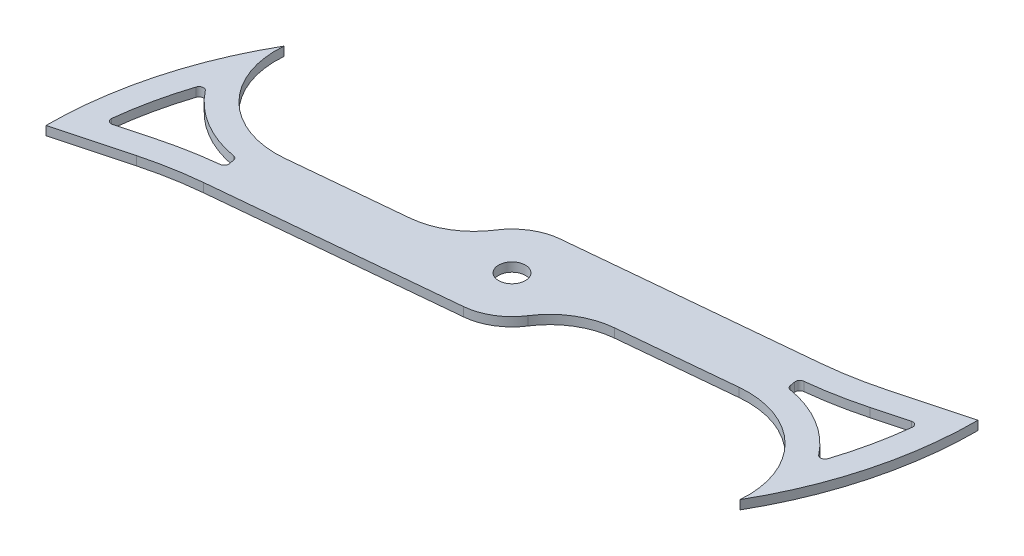
from build123d import *

# Parameters (mm, degrees)
SKETCH1_R           = 76.2
SKETCH1_R_2         = 19.05
BOSS_EXTRUDE1_DEPTH = 12.7
CIRPATTERN1_COUNT   = 2
FILLET1_R           = 101.6
CUT_EXTRUDE2_DEPTH  = 13.7
FILLET2_R           = 6.35


with BuildPart() as part:
    # Sketch1 → Boss-Extrude1 (new body)
    with BuildSketch(Plane(origin=(0, 0, 0), x_dir=(1, 0, 0), z_dir=(0, 1, 0))):
        with BuildLine():
            ThreePointArc((-461.937950379, 266.7), (-515.224835743, 138.054078658), (-533.4, 0))
            Line((-533.4, 0), (-431.8, 27.223637951))
            ThreePointArc((-431.8, 27.223637951), (-391.951998133, 36.135119544), (-351.499222019, 41.689456733))
            Line((-351.499222019, 41.689456733), (-14.198340678, 73.716868009))
            ThreePointArc((-14.198340678, 73.716868009), (-73.012974959, 93.516111014), (-97.595715318, 150.497336919))
            Line((-97.595715318, 150.497336919), (-323.429158368, 129.053987789))
            ThreePointArc((-323.429158368, 129.053987789), (-424.955630689, 165.402632783), (-461.937950379, 266.7))
        make_face()
        with Locations((-21.401289496, 149.575667949)):
            Circle(SKETCH1_R)
        with Locations((-21.401289496, 149.575667949)):
            Circle(SKETCH1_R_2, mode=Mode.SUBTRACT)
    boss_extrude1 = extrude(amount=BOSS_EXTRUDE1_DEPTH)

    # CirPattern1: Boss-Extrude1 ×2 about axis
    cirpattern1_axis = Axis((-21.401289496, 0, -149.575667949), (0, 1, 0))
    for i in range(1, CIRPATTERN1_COUNT):
        add(boss_extrude1.rotate(cirpattern1_axis, i * 360 / CIRPATTERN1_COUNT))

    # Fillet1
    fillet1_edges = [part.edges().sort_by_distance(p)[0] for p in [
        (-97.595715318, 6.35, -150.497336919),
        (54.793136326, 6.35, -148.653998979),
    ]]
    fillet(fillet1_edges, radius=FILLET1_R)

    # Sketch3 → Cut-Extrude2 (cut, through all)
    with BuildSketch(Plane(origin=(0, 12.7, 0), x_dir=(1, 0, 0), z_dir=(0, 1, 0))):
        with BuildLine():
            ThreePointArc((-354.80057356, 76.458073372), (-356.713011165, 85.800166676), (-358.363729661, 95.192038339))
            ThreePointArc((-358.363729661, 95.192038339), (-421.769213749, 118.496456117), (-470.148687166, 165.642801175))
            ThreePointArc((-470.148687166, 165.642801175), (-486.927538331, 106.671917768), (-496.339895031, 46.087245799))
            Line((-496.339895031, 46.087245799), (-440.83925515, 60.958597434))
            ThreePointArc((-440.83925515, 60.958597434), (-398.143908594, 70.506850222), (-354.80057356, 76.458073372))
        make_face()
        with BuildLine():
            ThreePointArc((398.036676158, 238.192738464), (355.341329602, 228.644485675), (311.997994568, 222.693262526))
            ThreePointArc((311.997994568, 222.693262526), (313.910432173, 213.351169222), (315.561150668, 203.959297559))
            ThreePointArc((315.561150668, 203.959297559), (378.966634757, 180.654879781), (427.346108174, 133.508534723))
            ThreePointArc((427.346108174, 133.508534723), (444.124959338, 192.47941813), (453.537316039, 253.064090099))
            Line((453.537316039, 253.064090099), (398.036676158, 238.192738464))
        make_face()
    extrude(amount=-CUT_EXTRUDE2_DEPTH, mode=Mode.SUBTRACT)

    # Fillet2
    fillet2_edges = [part.edges().sort_by_distance(p)[0] for p in [
        (-354.80057356, 6.35, -76.458073372),
        (-496.339895031, 6.35, -46.087245799),
        (-470.148687166, 6.35, -165.642801175),
        (-358.363729661, 6.35, -95.192038339),
        (311.997994568, 6.35, -222.693262526),
        (453.537316039, 6.35, -253.064090099),
        (427.346108174, 6.35, -133.508534723),
        (315.561150668, 6.35, -203.959297559),
    ]]
    fillet(fillet2_edges, radius=FILLET2_R)


solid = part.part
